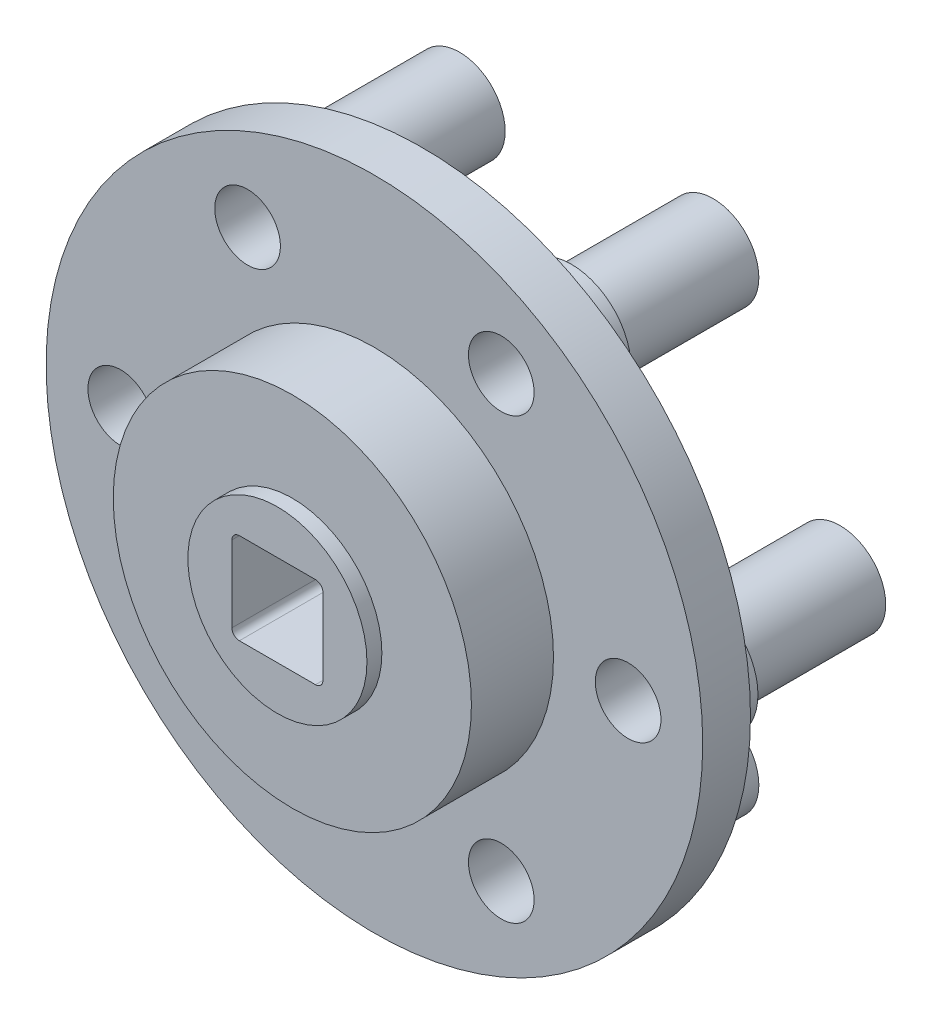
from build123d import *

# Parameters (mm, degrees)
SKETCH_1_W                   = 22
SKETCH_1_H                   = 1
SKETCH_2_R                   = 22
EXTRUDE_1_DEPTH              = 10
HOLE_WIZARD_M3_1_D           = 3.4
HOLE_WIZARD_M3_1_DEPTH       = 11
HOLE_WIZARD_M3_1_CBORE_D     = 4.5
HOLE_WIZARD_M3_1_CBORE_DEPTH = 6
HOLE_WIZARD_1_D              = 8
HOLE_WIZARD_1_DEPTH          = 5
HOLE_WIZARD_1_CBORE_D        = 10.16
HOLE_WIZARD_1_CBORE_DEPTH    = 3
HOLE_WIZARD_M3_2_D           = 3.4
HOLE_WIZARD_M3_2_DEPTH       = 22
HOLE_WIZARD_M3_2_CBORE_D     = 6.1
HOLE_WIZARD_M3_2_CBORE_DEPTH = 3
SKETCH_16_R                  = 2.4
EXTRUDE_2_DEPTH              = 11
SKETCH_17_R                  = 22
CUT_EXTRUDE_2_DEPTH          = 7.8
SKETCH_18_R                  = 12
EXTRUDE_3_DEPTH              = 5.5
SKETCH_19_R                  = 6
EXTRUDE_4_DEPTH              = 1
CUT_EXTRUDE_3_DEPTH          = 6
SKETCH_21_R                  = 2.2
CUT_EXTRUDE_4_DEPTH          = 3.5


with BuildPart() as part:
    # 草图1 → 旋转1 (revolve)
    with BuildSketch(Plane(origin=(0, 0, 0), x_dir=(1, 0, 0), z_dir=(0, 1, 0))):
        with Locations((11, 10.5)):
            Rectangle(SKETCH_1_W, SKETCH_1_H)
    revolve(axis=Axis((0, 0, -11), (0, 0, 1)))

    # 草图2 → 凸台-拉伸1 (add)
    with BuildSketch(Plane.XY.offset(-10)):
        Circle(SKETCH_2_R)
    extrude(amount=EXTRUDE_1_DEPTH)

    # 草图3 → 旋转2 (revolve)
    with BuildSketch(Plane(origin=(0, -14.722431864, 0), x_dir=(1, 0, 0), z_dir=(0, 1, 0))):
        Polygon((11.56, 22), (8.5, 22), (8.5, 11), (12.5, 11), (12.5, 12.5), (11.56, 12.5), align=None)
    revolve(axis=Axis((8.5, -14.722431864, -22), (0, 0, 1)))

    # 草图4 → 旋转3 (revolve)
    with BuildSketch(Plane(origin=(0, -14.722431864, 0), x_dir=(1, 0, 0), z_dir=(0, 1, 0))):
        Polygon((-5.44, 22), (-8.5, 22), (-8.5, 11), (-4.5, 11), (-4.5, 12.5), (-5.44, 12.5), align=None)
    revolve(axis=Axis((-8.5, -14.722431864, -22), (0, 0, 1)))

    # 草图5 → 旋转4 (revolve)
    with BuildSketch(Plane(origin=(0, 0, 0), x_dir=(1, 0, 0), z_dir=(0, 1, 0))):
        Polygon((-13.94, 22), (-17, 22), (-17, 11), (-13, 11), (-13, 12.5), (-13.94, 12.5), align=None)
    revolve(axis=Axis((-17, 0, -22), (0, 0, 1)))

    # 草图6 → 旋转5 (revolve)
    with BuildSketch(Plane(origin=(0, 14.722431864, 0), x_dir=(1, 0, 0), z_dir=(0, 1, 0))):
        Polygon((-5.44, 22), (-8.5, 22), (-8.5, 11), (-4.5, 11), (-4.5, 12.5), (-5.44, 12.5), align=None)
    revolve(axis=Axis((-8.5, 14.722431864, -22), (0, 0, 1)))

    # 草图7 → 旋转6 (revolve)
    with BuildSketch(Plane(origin=(0, 14.722431864, 0), x_dir=(1, 0, 0), z_dir=(0, 1, 0))):
        Polygon((11.56, 22), (8.5, 22), (8.5, 11), (12.5, 11), (12.5, 12.5), (11.56, 12.5), align=None)
    revolve(axis=Axis((8.5, 14.722431864, -22), (0, 0, 1)))

    # 草图8 → 旋转7 (revolve)
    with BuildSketch(Plane(origin=(0, 0, 0), x_dir=(1, 0, 0), z_dir=(0, 1, 0))):
        Polygon((20.06, 22), (17, 22), (17, 11), (21, 11), (21, 12.5), (20.06, 12.5), align=None)
    revolve(axis=Axis((17, 0, -22), (0, 0, 1)))

    # M3 六角头机械螺钉的柱形沉头孔1
    with Locations(Plane(origin=(0, 0, -11), x_dir=(-1, 0, 0), z_dir=(0, 0, -1))):
        with Locations((15.588457268, 9), (0, 18), (-15.588457268, 9), (-15.588457268, -9), (0, -18), (15.588457268, -9)):
            CounterBoreHole(HOLE_WIZARD_M3_1_D / 2, HOLE_WIZARD_M3_1_CBORE_D / 2, HOLE_WIZARD_M3_1_CBORE_DEPTH, depth=HOLE_WIZARD_M3_1_DEPTH)

    # 孔1
    with Locations(Plane(origin=(0, 0, -11), x_dir=(-1, 0, 0), z_dir=(0, 0, -1))):
        with Locations((0, 0)):
            CounterBoreHole(HOLE_WIZARD_1_D / 2, HOLE_WIZARD_1_CBORE_D / 2, HOLE_WIZARD_1_CBORE_DEPTH, depth=HOLE_WIZARD_1_DEPTH)

    # M3 六角头机械螺钉的柱形沉头孔2
    with Locations(Plane.XY):
        with Locations((8.5, -14.722431864), (-8.5, -14.722431864), (-17, 0), (-8.5, 14.722431864), (8.5, 14.722431864), (17, 0)):
            CounterBoreHole(HOLE_WIZARD_M3_2_D / 2, HOLE_WIZARD_M3_2_CBORE_D / 2, HOLE_WIZARD_M3_2_CBORE_DEPTH, depth=HOLE_WIZARD_M3_2_DEPTH)

    # 草图16 → 凸台-拉伸2 (add)
    with BuildSketch(Plane.XY):
        with Locations((-15.588457268, 9)):
            Circle(SKETCH_16_R)
        with Locations((0, 18)):
            Circle(SKETCH_16_R)
        with Locations((15.588457268, 9)):
            Circle(SKETCH_16_R)
        with Locations((15.588457268, -9)):
            Circle(SKETCH_16_R)
        with Locations((0, -18)):
            Circle(SKETCH_16_R)
        with Locations((-15.588457268, -9)):
            Circle(SKETCH_16_R)
    extrude(amount=-EXTRUDE_2_DEPTH)

    # 草图17 → 切除-拉伸2 (cut)
    with BuildSketch(Plane.XY):
        Circle(SKETCH_17_R)
    extrude(amount=-CUT_EXTRUDE_2_DEPTH, mode=Mode.SUBTRACT)

    # 草图18 → 凸台-拉伸3 (add)
    with BuildSketch(Plane.XY.offset(-7.8)):
        Circle(SKETCH_18_R)
    extrude(amount=EXTRUDE_3_DEPTH)

    # 草图19 → 凸台-拉伸4 (add)
    with BuildSketch(Plane.XY.offset(-2.3)):
        Circle(SKETCH_19_R)
    extrude(amount=EXTRUDE_4_DEPTH)

    # 草图20 → 切除-拉伸3 (cut)
    with BuildSketch(Plane.XY.offset(-1.3)):
        with BuildLine():
            Line((-2.55, 3.05), (2.55, 3.05))
            ThreePointArc((2.55, 3.05), (2.903553391, 2.903553391), (3.05, 2.55))
            Line((3.05, 2.55), (3.05, -2.55))
            ThreePointArc((3.05, -2.55), (2.903553391, -2.903553391), (2.55, -3.05))
            Line((2.55, -3.05), (-2.55, -3.05))
            ThreePointArc((-2.55, -3.05), (-2.903553391, -2.903553391), (-3.05, -2.55))
            Line((-3.05, -2.55), (-3.05, 2.55))
            ThreePointArc((-3.05, 2.55), (-2.903553391, 2.903553391), (-2.55, 3.05))
        make_face()
    extrude(amount=-CUT_EXTRUDE_3_DEPTH, mode=Mode.SUBTRACT)

    # 草图21 → 切除-拉伸4 (cut)
    with BuildSketch(Plane.XY.offset(-7.8)):
        with Locations((-8.5, -14.722431864)):
            Circle(SKETCH_21_R)
        with Locations((-17, 0)):
            Circle(SKETCH_21_R)
        with Locations((-8.5, 14.722431864)):
            Circle(SKETCH_21_R)
        with Locations((8.5, 14.722431864)):
            Circle(SKETCH_21_R)
        with Locations((17, 0)):
            Circle(SKETCH_21_R)
        with Locations((8.5, -14.722431864)):
            Circle(SKETCH_21_R)
    extrude(amount=-CUT_EXTRUDE_4_DEPTH, mode=Mode.SUBTRACT)


solid = part.part
